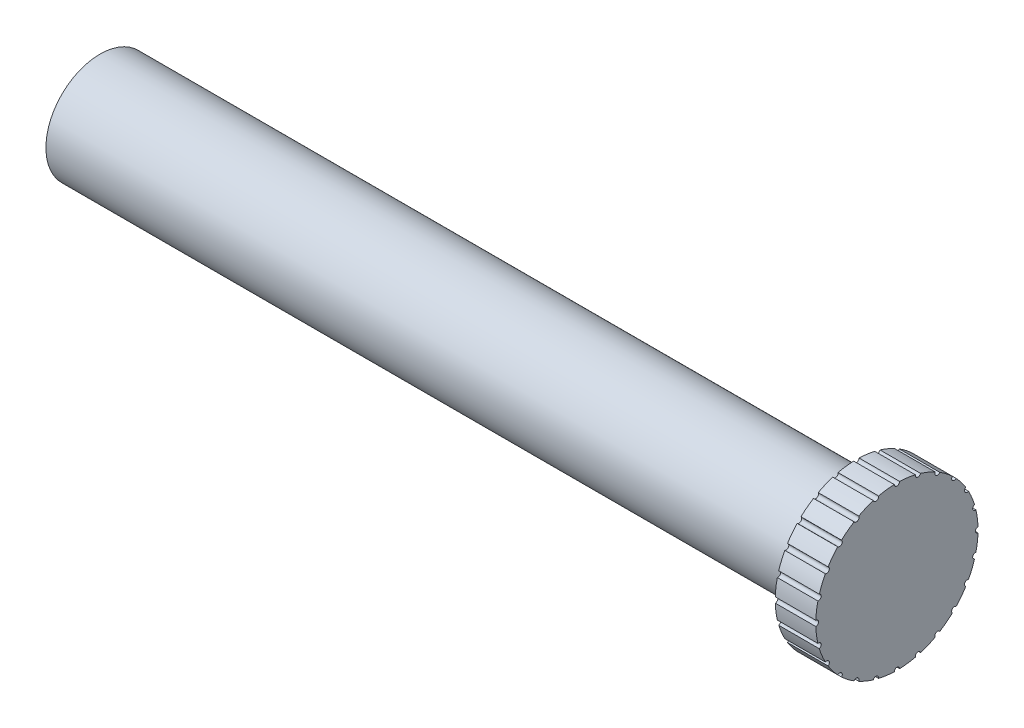
from build123d import *

# Parameters (mm, degrees)
SKETCH1_R           = 4
BOSS_EXTRUDE2_DEPTH = 55.94
SKETCH2_R           = 6
BOSS_EXTRUDE3_DEPTH = 3
SKETCH3_R           = 0.2
CUT_EXTRUDE1_DEPTH  = 3
CIRPATTERN1_COUNT   = 24


with BuildPart() as part:
    # Sketch1 → Boss-Extrude2 (new body)
    with BuildSketch(Plane(origin=(0, 0, 0), x_dir=(0, 0, -1), z_dir=(1, 0, 0))):
        Circle(SKETCH1_R)
    extrude(amount=BOSS_EXTRUDE2_DEPTH)

    # Sketch2 → Boss-Extrude3 (add)
    with BuildSketch(Plane(origin=(55.94, 0, 0), x_dir=(0, 0, -1), z_dir=(1, 0, 0))):
        Circle(SKETCH2_R)
    extrude(amount=BOSS_EXTRUDE3_DEPTH)

    # Sketch3 → Cut-Extrude1 (cut)
    with BuildSketch(Plane(origin=(58.94, 0, 0), x_dir=(0, 0, -1), z_dir=(1, 0, 0))):
        with Locations((-6, 0)):
            Circle(SKETCH3_R)
    cut_extrude1 = extrude(amount=-CUT_EXTRUDE1_DEPTH, mode=Mode.SUBTRACT)

    # CirPattern1: Cut-Extrude1 ×24 about axis
    cirpattern1_axis = Axis((0, 0, -0.003264402), (1, 0, 0))
    for i in range(1, CIRPATTERN1_COUNT):
        add(cut_extrude1.rotate(cirpattern1_axis, i * 360 / CIRPATTERN1_COUNT), mode=Mode.SUBTRACT)


solid = part.part
